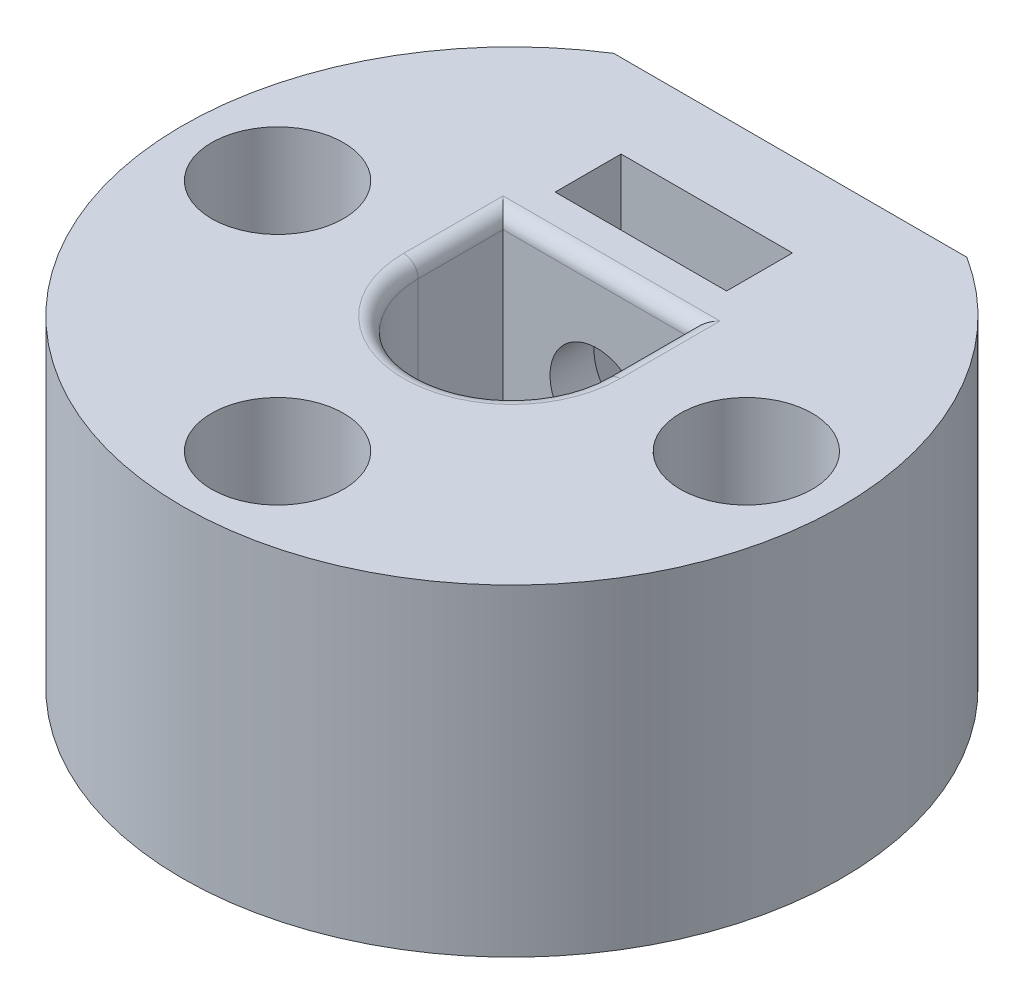
from build123d import *

# Parameters (mm, degrees)
BOSS_EXTRU_1_DEPTH                              = 8
CONG_1_R                                        = 0.5
ESQUISSE6_R                                     = 1.6
ENL_V_MAT_EXTRU_1_DEPTH                         = 10.5
ESQUISSE7_W                                     = 5.85
ESQUISSE7_H                                     = 2.25
ENL_V_MAT_EXTRU_2_DEPTH                         = 9.0000001
BOSS_EXTRU_2_DEPTH                              = 3
CHAMBRAGE_POUR_VIS_T_TE_CYLINDRIQUE_D           = 2.5
CHAMBRAGE_POUR_VIS_T_TE_CYLINDRIQUE_CBORE_D     = 4.5
CHAMBRAGE_POUR_VIS_T_TE_CYLINDRIQUE_CBORE_DEPTH = 5.3
ESQUISSE14_R                                    = 4.25
ENL_V_MAT_EXTRU_3_DEPTH                         = 2


with BuildPart() as part:
    # Esquisse1 → Boss.-Extru.1 (new body)
    with BuildSketch(Plane(origin=(0, 0, 0), x_dir=(1, 0, 0), z_dir=(0, 1, 0))):
        with BuildLine():
            Line((6.025985397, 9.5), (-6.025985397, 9.5))
            ThreePointArc((-6.025985397, 9.5), (0, -11.25), (6.025985397, 9.5))
        make_face()
        with BuildLine():
            Line((-3.2, 0), (-3.2, 2.9))
            Line((-3.2, 2.9), (3.2, 2.9))
            Line((3.2, 2.9), (3.2, 0))
            ThreePointArc((3.2, 0), (0, -3.2), (-3.2, 0))
        make_face(mode=Mode.SUBTRACT)
    extrude(amount=BOSS_EXTRU_1_DEPTH)

    # Congé1
    cong_1_edges = [part.edges().sort_by_distance(p)[0] for p in [
        (0, 8, 3.2),
        (3.2, 8, -1.45),
        (0, 8, -2.9),
        (-3.2, 8, -1.45),
    ]]
    fillet(cong_1_edges, radius=CONG_1_R)

    # Esquisse6 → Enlèv. mat.-Extru.1 (cut, through all)
    with BuildSketch(Plane.XY):
        with Locations((0, 4)):
            Circle(ESQUISSE6_R)
    extrude(amount=-ENL_V_MAT_EXTRU_1_DEPTH, mode=Mode.SUBTRACT)

    # Esquisse7 → Enlèv. mat.-Extru.2 (cut, through all)
    with BuildSketch(Plane(origin=(0, 0, 0), x_dir=(1, 0, 0), z_dir=(0, 1, 0))):
        with Locations((0, 5.525)):
            Rectangle(ESQUISSE7_W, ESQUISSE7_H)
    extrude(amount=ENL_V_MAT_EXTRU_2_DEPTH, mode=Mode.SUBTRACT)

    # Esquisse8 → Boss.-Extru.2 (add)
    with BuildSketch(Plane.XZ):
        with BuildLine():
            Line((-6.025985397, -9.5), (6.025985397, -9.5))
            ThreePointArc((6.025985397, -9.5), (0, 11.25), (-6.025985397, -9.5))
        make_face()
    extrude(amount=BOSS_EXTRU_2_DEPTH)

    # Chambrage pour vis à tête cylindrique à 6 pans creux (ou vis CHC) M21 (through all)
    with Locations(Plane(origin=(0, 8, 0), x_dir=(1, 0, 0), z_dir=(0, 1, 0))):
        with Locations((-8, 0), (0, -8), (8, 0)):
            CounterBoreHole(CHAMBRAGE_POUR_VIS_T_TE_CYLINDRIQUE_D / 2, CHAMBRAGE_POUR_VIS_T_TE_CYLINDRIQUE_CBORE_D / 2, CHAMBRAGE_POUR_VIS_T_TE_CYLINDRIQUE_CBORE_DEPTH)

    # Esquisse14 → Enlèv. mat.-Extru.3 (cut)
    with BuildSketch(Plane.XZ.offset(3)):
        Circle(ESQUISSE14_R)
    extrude(amount=-ENL_V_MAT_EXTRU_3_DEPTH, mode=Mode.SUBTRACT)


solid = part.part
